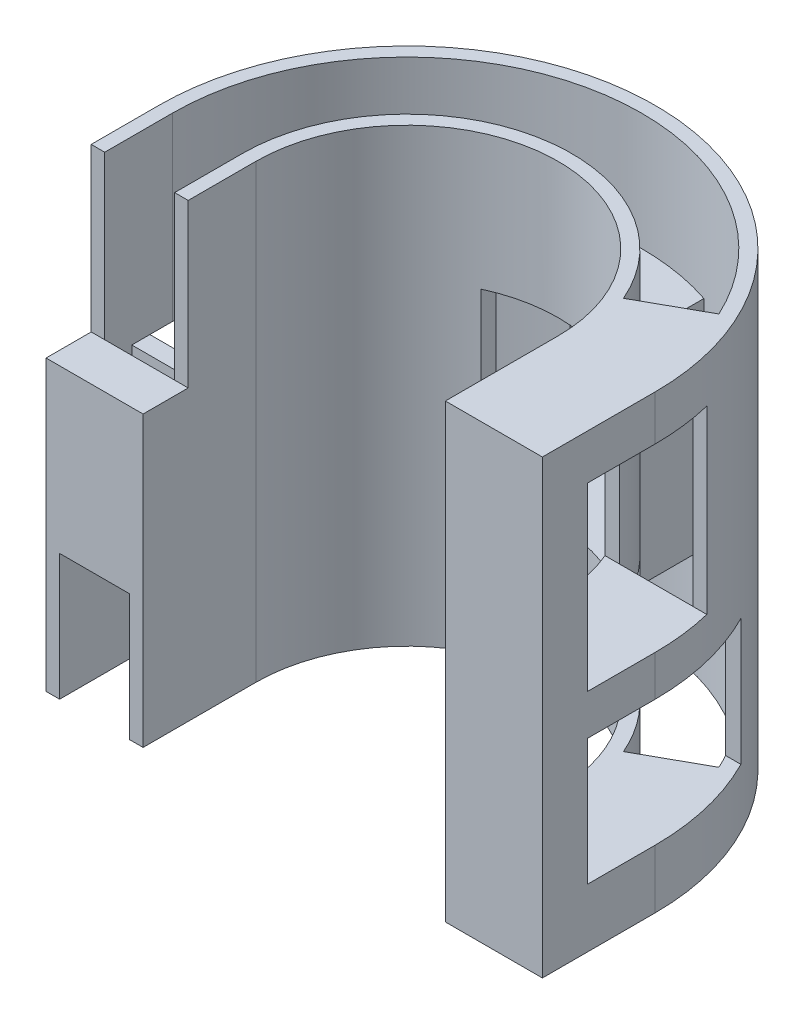
from build123d import *

# Parameters (mm, degrees)
SKETCH2_R            = 27.5
BOSS_EXTRUDE1_DEPTH  = 50
SKETCH3_R            = 26
CUT_EXTRUDE1_DEPTH   = 51
SKETCH7_R            = 18.25
BOSS_EXTRUDE3_DEPTH  = 50
SKETCH8_R            = 16.75
CUT_EXTRUDE3_DEPTH   = 51
SKETCH9_W            = 59.961193285
SKETCH9_H            = 28.516087398
CUT_EXTRUDE4_DEPTH   = 51
SKETCH10_W           = 1.5
SKETCH10_H           = 12.5
BOSS_EXTRUDE4_DEPTH  = 50
BOSS_EXTRUDE5_DEPTH  = 5
BOSS_EXTRUDE6_DEPTH  = 6.5
SKETCH12_W           = 14
SKETCH12_H           = 20
SKETCH12_W_2         = 20
SKETCH12_H_2         = 14
CUT_EXTRUDE6_DEPTH   = 15
SKETCH14_W           = 14
SKETCH14_H           = 20
CUT_EXTRUDE7_DEPTH   = 45
SKETCH15_W           = 16.605878589
SKETCH15_H           = 22.2356131
CUT_EXTRUDE8_DEPTH   = 15
BOSS_EXTRUDE8_DEPTH  = 4.5
BOSS_EXTRUDE9_DEPTH  = 2
BOSS_EXTRUDE10_DEPTH = 2
BOSS_EXTRUDE15_DEPTH = 24
BOSS_EXTRUDE17_DEPTH = 10
SKETCH26_W           = 5
SKETCH26_H           = 18
BOSS_EXTRUDE18_DEPTH = 10
SKETCH27_W           = 7.75
SKETCH27_H           = 14
BOSS_EXTRUDE19_DEPTH = 5
SKETCH29_W           = 14
SKETCH29_H           = 20
CUT_EXTRUDE9_DEPTH   = 8
SKETCH30_W           = 2
SKETCH30_H           = 20
BOSS_EXTRUDE20_DEPTH = 10


with BuildPart() as part:
    # Sketch2 → Boss-Extrude1 (new body)
    with BuildSketch(Plane(origin=(0, 0, 0), x_dir=(1, 0, 0), z_dir=(0, 1, 0))):
        Circle(SKETCH2_R)
    extrude(amount=BOSS_EXTRUDE1_DEPTH)

    # Sketch3 → Cut-Extrude1 (cut, through all)
    with BuildSketch(Plane(origin=(0, 50, 0), x_dir=(1, 0, 0), z_dir=(0, 1, 0))):
        Circle(SKETCH3_R)
    extrude(amount=-CUT_EXTRUDE1_DEPTH, mode=Mode.SUBTRACT)


with BuildPart() as body_2:
    # Sketch7 → Boss-Extrude3 (new body)
    with BuildSketch(Plane(origin=(0, 50, 0), x_dir=(1, 0, 0), z_dir=(0, 1, 0))):
        Circle(SKETCH7_R)
    extrude(amount=-BOSS_EXTRUDE3_DEPTH)

    # Sketch8 → Cut-Extrude3 (cut, through all)
    with BuildSketch(Plane(origin=(0, 50, 0), x_dir=(1, 0, 0), z_dir=(0, 1, 0))):
        Circle(SKETCH8_R)
    extrude(amount=-CUT_EXTRUDE3_DEPTH, mode=Mode.SUBTRACT)


with BuildPart() as cut_extrude4_tool:
    # Sketch9 → Cut-Extrude4 (new body, through all)
    with BuildSketch(Plane(origin=(0, 50, 0), x_dir=(1, 0, 0), z_dir=(0, 1, 0))):
        with Locations((-0.477134602, -14.258043699)):
            Rectangle(SKETCH9_W, SKETCH9_H)
    extrude(amount=-CUT_EXTRUDE4_DEPTH)


with BuildPart() as part_1:
    add(part.part)

    # Cut-Extrude4: cut by cut_extrude4_tool
    add(cut_extrude4_tool.part, mode=Mode.SUBTRACT)



with BuildPart() as body_2_1:
    add(body_2.part)

    # Cut-Extrude4: cut by cut_extrude4_tool
    add(cut_extrude4_tool.part, mode=Mode.SUBTRACT)


with BuildPart() as part_2:
    add(part_1.part)

    add(body_2_1.part)  # Boss-Extrude4 merges body 2
    # Sketch10 → Boss-Extrude4 (add)
    with BuildSketch(Plane(origin=(0, 50, 0), x_dir=(1, 0, 0), z_dir=(0, 1, 0))):
        with Locations((-26.75, -6.25)):
            Rectangle(SKETCH10_W, SKETCH10_H)
        with Locations((-17.5, -6.25)):
            Rectangle(SKETCH10_W, SKETCH10_H)
        with Locations((17.5, -6.25)):
            Rectangle(SKETCH10_W, SKETCH10_H)
        with Locations((26.75, -6.25)):
            Rectangle(SKETCH10_W, SKETCH10_H)
    extrude(amount=-BOSS_EXTRUDE4_DEPTH)

    # Sketch11 → Boss-Extrude5 (add)
    with BuildSketch(Plane(origin=(0, 50, 0), x_dir=(1, 0, 0), z_dir=(0, 1, 0))):
        with BuildLine():
            Line((16.760723177, 7.220848882), (23.556882961, 11.003329731))
            ThreePointArc((23.556882961, 11.003329731), (25.38187303, 5.63564739), (26, 0))
            Line((26, 0), (26, -12.5))
            Line((26, -12.5), (18.25, -12.5))
            Line((18.25, -12.5), (18.25, 0))
            ThreePointArc((18.25, 0), (17.873803428, 3.686414384), (16.760723177, 7.220848882))
        make_face()
    extrude(amount=-BOSS_EXTRUDE5_DEPTH)

    # Sketch13 → Boss-Extrude6 (add)
    with BuildSketch(Plane.XZ):
        with BuildLine():
            Line((18.25, 0), (18.25, 12.5))
            Line((18.25, 12.5), (26, 12.5))
            Line((26, 12.5), (26, 0))
            ThreePointArc((26, 0), (25.38187303, -5.63564739), (23.556882961, -11.003329731))
            Line((23.556882961, -11.003329731), (16.760723177, -7.220848882))
            ThreePointArc((16.760723177, -7.220848882), (17.873803428, -3.686414384), (18.25, 0))
        make_face()
    extrude(amount=-BOSS_EXTRUDE6_DEPTH)

    # Sketch12 → Cut-Extrude6 (cut)
    with BuildSketch(Plane(origin=(27.5, 0, 0), x_dir=(0, 0, -1), z_dir=(1, 0, 0))):
        with Locations((-0.5, 35)):
            Rectangle(SKETCH12_W, SKETCH12_H)
        with Locations((2.5, 13.5)):
            Rectangle(SKETCH12_W_2, SKETCH12_H_2)
    extrude(amount=-CUT_EXTRUDE6_DEPTH, mode=Mode.SUBTRACT)

    # Sketch14 → Cut-Extrude7 (cut)
    with BuildSketch(Plane.XY.offset(12.5)):
        with Locations((0, 25)):
            Rectangle(SKETCH14_W, SKETCH14_H)
    extrude(amount=-CUT_EXTRUDE7_DEPTH, mode=Mode.SUBTRACT)

    # Sketch15 → Cut-Extrude8 (cut)
    with BuildSketch(Plane.ZY.offset(27.5)):
        with Locations((15.802939295, 43.11780655)):
            Rectangle(SKETCH15_W, SKETCH15_H)
    extrude(amount=-CUT_EXTRUDE8_DEPTH, mode=Mode.SUBTRACT)

    # Sketch17 → Boss-Extrude8 (add)
    with BuildSketch(Plane(origin=(0, 25, 0), x_dir=(1, 0, 0), z_dir=(0, 1, 0))):
        with BuildLine():
            Line((26.720778432, 6.5), (17.053225501, 6.5))
            ThreePointArc((17.053225501, 6.5), (17.948312809, 3.304628164), (18.25, 0))
            Line((18.25, 0), (18.25, -7.5))
            Line((18.25, -7.5), (27.5, -7.5))
            Line((27.5, -7.5), (27.5, 0))
            ThreePointArc((27.5, 0), (27.304499692, 3.273270011), (26.720778432, 6.5))
        make_face()
    extrude(amount=-BOSS_EXTRUDE8_DEPTH)

    # Sketch18 → Boss-Extrude9 (add)
    with BuildSketch(Plane.XZ.offset(-35)):
        with BuildLine():
            Line((-7, -16.854153791), (-7, -25.039968051))
            ThreePointArc((-7, -25.039968051), (0, -26), (7, -25.039968051))
            Line((7, -25.039968051), (7, -16.854153791))
            ThreePointArc((7, -16.854153791), (0, -18.25), (-7, -16.854153791))
        make_face()
    extrude(amount=-BOSS_EXTRUDE9_DEPTH)

    # Sketch19 → Boss-Extrude10 (add)
    with BuildSketch(Plane(origin=(0, 15, 0), x_dir=(1, 0, 0), z_dir=(0, 1, 0))):
        with BuildLine():
            Line((7, 25.039968051), (7, 16.854153791))
            ThreePointArc((7, 16.854153791), (0, 18.25), (-7, 16.854153791))
            Line((-7, 16.854153791), (-7, 25.039968051))
            ThreePointArc((-7, 25.039968051), (0, 26), (7, 25.039968051))
        make_face()
    extrude(amount=-BOSS_EXTRUDE10_DEPTH)

    # Sketch24 → Boss-Extrude15 (add)
    with BuildSketch(Plane(origin=(0, 37, 0), x_dir=(1, 0, 0), z_dir=(0, 1, 0))):
        with BuildLine():
            Line((8.237316258, 24.660628963), (8.237316258, 16.285242426))
            ThreePointArc((8.237316258, 16.285242426), (7.6239666, 16.581243418), (7, 16.854153791))
            Line((7, 16.854153791), (7, 25.039968051))
            ThreePointArc((7, 25.039968051), (7.621018713, 24.857998185), (8.237316258, 24.660628963))
        make_face()
    extrude(amount=-BOSS_EXTRUDE15_DEPTH)

    # Sketch25 → Boss-Extrude17 (add)
    with BuildSketch(Plane(origin=(27.5, 0, 0), x_dir=(0, 0, -1), z_dir=(1, 0, 0))):
        Polygon((-7.5, 45), (-12.5, 45), (-12.5, 25), (-12.5, 20.5), (-7.5, 20.5), (-7.5, 25), align=None)
    extrude(amount=-BOSS_EXTRUDE17_DEPTH)

    # Sketch26 → Boss-Extrude18 (add)
    with BuildSketch(Plane.ZY.offset(27.5)):
        with Locations((10, 23)):
            Rectangle(SKETCH26_W, SKETCH26_H)
    extrude(amount=-BOSS_EXTRUDE18_DEPTH)

    # Sketch27 → Boss-Extrude19 (add)
    with BuildSketch(Plane.XY.offset(12.5)):
        with Locations((22.125, 13.5)):
            Rectangle(SKETCH27_W, SKETCH27_H)
    extrude(amount=-BOSS_EXTRUDE19_DEPTH)

    # Sketch29 → Cut-Extrude9 (cut)
    with BuildSketch(Plane.ZY.offset(27.5)):
        with Locations((-4.5, 20)):
            Rectangle(SKETCH29_W, SKETCH29_H)
    extrude(amount=-CUT_EXTRUDE9_DEPTH, mode=Mode.SUBTRACT)

    # Sketch30 → Boss-Extrude20 (add)
    with BuildSketch(Plane.ZY.offset(27.5)):
        with Locations((3.5, 20)):
            Rectangle(SKETCH30_W, SKETCH30_H)
    extrude(amount=-BOSS_EXTRUDE20_DEPTH)


solid = part_2.part
